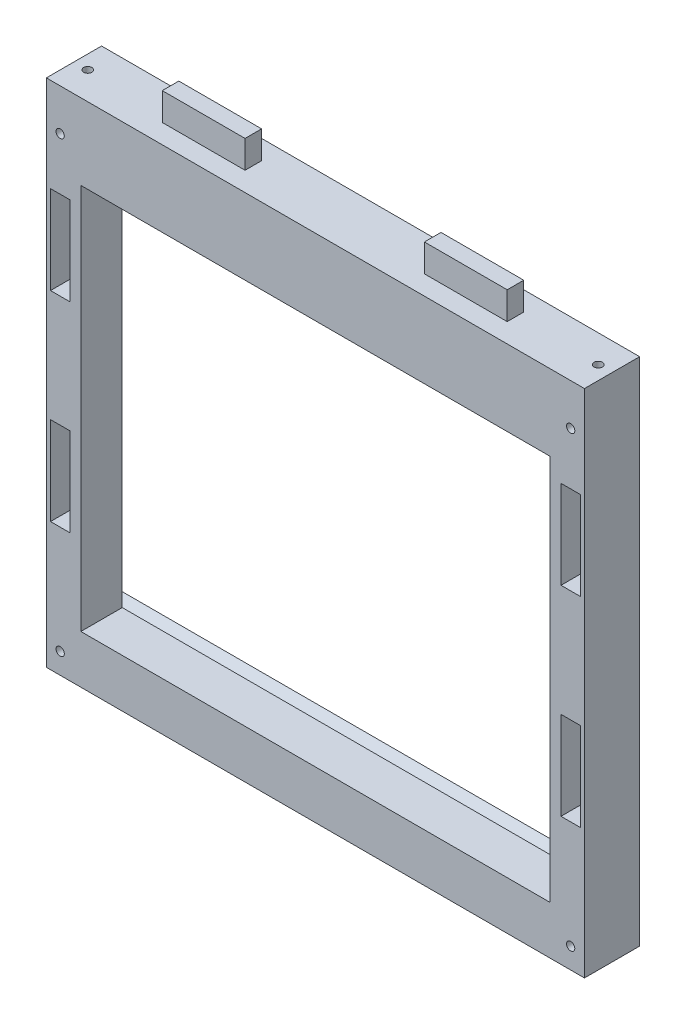
from build123d import *

# Parameters (mm, degrees)
ESBO_O1_W                = 195
ESBO_O1_H                = 185
RESSALTO_EXTRUS_O1_DEPTH = 20
ESBO_O3_W                = 7
ESBO_O3_H                = 32
CORTE_EXTRUS_O1_DEPTH    = 10
ESBO_O6_R                = 1.5
CORTE_EXTRUS_O4_DEPTH    = 21
ESBO_O8_W                = 170
ESBO_O8_H                = 140
CORTE_EXTRUS_O6_DEPTH    = 21
CORTE_EXTRUS_O7_DEPTH    = 190
ESBO_O10_W               = 30
ESBO_O10_H               = 6
RESSALTO_EXTRUS_O2_DEPTH = 10
ESBO_O11_R               = 1.5
CORTE_EXTRUS_O8_DEPTH    = 8


with BuildPart() as part:
    # Esboço1 → Ressalto-extrusão1 (new body)
    with BuildSketch(Plane.XY):
        Rectangle(ESBO_O1_W, ESBO_O1_H)
    extrude(amount=RESSALTO_EXTRUS_O1_DEPTH)

    # Esboço3 → Corte-extrusão1 (cut)
    with BuildSketch(Plane.XY.offset(20)):
        with Locations((-92.5, -30)):
            Rectangle(ESBO_O3_W, ESBO_O3_H)
        with Locations((92.5, -30)):
            Rectangle(ESBO_O3_W, ESBO_O3_H)
        with Locations((92.5, 42.5)):
            Rectangle(ESBO_O3_W, ESBO_O3_H)
        with Locations((-92.5, 42.5)):
            Rectangle(ESBO_O3_W, ESBO_O3_H)
    extrude(amount=-CORTE_EXTRUS_O1_DEPTH, mode=Mode.SUBTRACT)

    # Esboço6 → Corte-extrusão4 (cut, through all)
    with BuildSketch(Plane(origin=(0, 0, 0), x_dir=(-1, 0, 0), z_dir=(0, 0, -1))):
        with Locations((-92.5, 77.5)):
            Circle(ESBO_O6_R)
        with Locations((92.5, 77.5)):
            Circle(ESBO_O6_R)
        with Locations((-92.5, -85)):
            Circle(ESBO_O6_R)
        with Locations((92.5, -85)):
            Circle(ESBO_O6_R)
    extrude(amount=-CORTE_EXTRUS_O4_DEPTH, mode=Mode.SUBTRACT)

    # Esboço8 → Corte-extrusão6 (cut, through all)
    with BuildSketch(Plane(origin=(0, 0, 0), x_dir=(-1, 0, 0), z_dir=(0, 0, -1))):
        with Locations((0, -5)):
            Rectangle(ESBO_O8_W, ESBO_O8_H)
    extrude(amount=-CORTE_EXTRUS_O6_DEPTH, mode=Mode.SUBTRACT)

    # Esboço9 → Corte-extrusão7 (cut)
    with BuildSketch(Plane.ZY.offset(97.5)):
        Polygon((0, -75), (0, 65), (5, 68.501037691), (5, -78.501037691), align=None)
    extrude(amount=-CORTE_EXTRUS_O7_DEPTH, mode=Mode.SUBTRACT)

    # Esboço10 → Ressalto-extrusão2 (add)
    with BuildSketch(Plane(origin=(0, 92.5, 0), x_dir=(1, 0, 0), z_dir=(0, 1, 0))):
        with Locations((-47.5, -10)):
            Rectangle(ESBO_O10_W, ESBO_O10_H)
        with Locations((47.5, -10)):
            Rectangle(ESBO_O10_W, ESBO_O10_H)
    extrude(amount=RESSALTO_EXTRUS_O2_DEPTH)

    # Esboço11 → Corte-extrusão8 (cut)
    with BuildSketch(Plane(origin=(0, 92.5, 0), x_dir=(1, 0, 0), z_dir=(0, 1, 0))):
        with Locations((-92.5, -10)):
            Circle(ESBO_O11_R)
        with Locations((92.5, -10)):
            Circle(ESBO_O11_R)
    extrude(amount=-CORTE_EXTRUS_O8_DEPTH, mode=Mode.SUBTRACT)


solid = part.part
